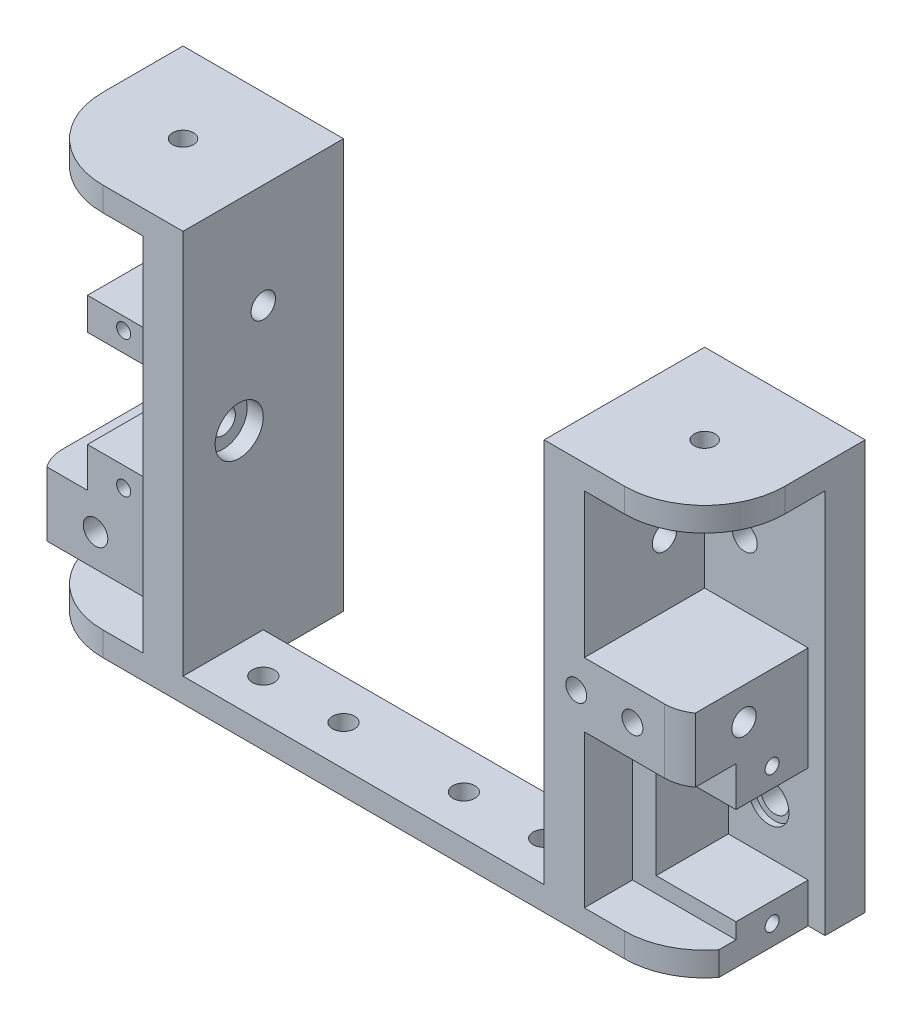
from build123d import *

# Parameters (mm, degrees)
SKETCH1_R                 = 1.75
SKETCH1_R_2               = 1.525
SKETCH1_R_3               = 1.55
MAIN_FLANGE_DEPTH         = 5
SKETCH2_W                 = 15
SKETCH2_H                 = 45
SKETCH2_R                 = 1.525
SIDE_FLANGE_DEPTH         = 5
SKETCH11_R                = 1.3
BOSS_EXTRUDE3_DEPTH       = 3
BOSS_EXTRUDE4_DEPTH       = 7
SKETCH16_R                = 1.3
TOP_SUPPORT_DEPTH         = 3
SKETCH18_W                = 15
SKETCH18_H                = 8
SKETCH18_R                = 1.525
BOSS_EXTRUDE5_DEPTH       = 15
SKETCH19_W                = 15
SKETCH19_H                = 8
SKETCH19_R                = 1.525
BOSS_EXTRUDE6_DEPTH       = 15
FILLET1_R                 = 5
M3X0_5_TAPPED_HOLE1_D     = 2.6
M3X0_5_TAPPED_HOLE1_DEPTH = 7.5
M3X0_5_TAPPED_HOLE1_TIP   = 0.781118805
M3X0_5_TAPPED_HOLE2_D     = 2.6
M3X0_5_TAPPED_HOLE2_DEPTH = 7.5
M3X0_5_TAPPED_HOLE2_TIP   = 0.781118805
SKETCH24_R                = 2.5
CUT_EXTRUDE1_DEPTH        = 0.75
SKETCH25_R                = 2.5
CUT_EXTRUDE2_DEPTH        = 0.75
SKETCH26_W                = 10
SKETCH26_H                = 2.85
BOSS_EXTRUDE7_DEPTH       = 10
MOTOR_MOUNT_DEPTH         = 9
SKETCH33_W                = 15
SKETCH33_H                = 30
CUT_EXTRUDE6_DEPTH        = 2.1
SKETCH34_R                = 0.875
CUT_EXTRUDE7_DEPTH        = 7
BOSS_EXTRUDE9_DEPTH       = 9
SKETCH36_W                = 15
SKETCH36_H                = 29.05
CUT_EXTRUDE8_DEPTH        = 2.1
SKETCH37_R                = 0.875
CUT_EXTRUDE9_DEPTH        = 7
SKETCH39_W                = 45
SKETCH39_H                = 10
CUT_EXTRUDE11_DEPTH       = 52
SKETCH40_R                = 1.375
MOUNT_HOLES_DEPTH         = 4.0000001
SKETCH41_R                = 3
BEARING_HOLDER_DEPTH      = 2
SKETCH42_R                = 3
CUT_EXTRUDE14_DEPTH       = 2


with BuildPart() as part:
    # Sketch1 → main flange (new body)
    with BuildSketch(Plane.XY):
        Polygon((-22.5, 7), (0, 7), (22.5, 7), (22.5, 45), (42.5, 45), (42.5, 0), (-42.5, 0), (-42.5, 45), (-22.5, 45), align=None)
        with Locations((35.5, 8)):
            Circle(SKETCH1_R, mode=Mode.SUBTRACT)
        with Locations((-35.5, 8)):
            Circle(SKETCH1_R_2, mode=Mode.SUBTRACT)
        with Locations((32.5, 35)):
            Circle(SKETCH1_R_3, mode=Mode.SUBTRACT)
        with Locations((-32.5, 35)):
            Circle(SKETCH1_R_3, mode=Mode.SUBTRACT)
    extrude(amount=MAIN_FLANGE_DEPTH)

    # Sketch2 → side flange (add)
    with BuildSketch(Plane(origin=(22.5, 0, 0), x_dir=(0, 0, -1), z_dir=(1, 0, 0))):
        with Locations((-12.5, 22.5)):
            Rectangle(SKETCH2_W, SKETCH2_H)
        with Locations((-13, 23)):
            Circle(SKETCH2_R, mode=Mode.SUBTRACT)
        with Locations((-10, 35)):
            Circle(SKETCH2_R, mode=Mode.SUBTRACT)
    side_flange = extrude(amount=SIDE_FLANGE_DEPTH)

    # Mirror1: side flange across plane
    add(side_flange.mirror(Plane(origin=(0, 0, 0), x_dir=(0, 0, 1), z_dir=(1, 0, 0))))

    # Sketch11 → Boss-Extrude3 (add)
    with BuildSketch(Plane.XZ):
        with BuildLine():
            Line((-42.5, 0), (42.5, 0))
            Line((42.5, 0), (42.5, 10))
            ThreePointArc((42.5, 10), (39.571067812, 17.071067812), (32.5, 20))
            Line((32.5, 20), (-32.5, 20))
            ThreePointArc((-32.5, 20), (-39.571067812, 17.071067812), (-42.5, 10))
            Line((-42.5, 10), (-42.5, 0))
        make_face()
        with Locations((-32.5, 10)):
            Circle(SKETCH11_R, mode=Mode.SUBTRACT)
        with Locations((32.5, 10)):
            Circle(SKETCH11_R, mode=Mode.SUBTRACT)
    extrude(amount=BOSS_EXTRUDE3_DEPTH)

    # Sketch12 → Boss-Extrude4 (add)
    with BuildSketch(Plane(origin=(0, 0, 0), x_dir=(1, 0, 0), z_dir=(0, 1, 0))):
        with BuildLine():
            Line((-4, -3), (-4, 0))
            Line((-4, 0), (4, 0))
            Line((4, 0), (4, -3))
            ThreePointArc((4, -3), (0, -7), (-4, -3))
        make_face()
    extrude(amount=BOSS_EXTRUDE4_DEPTH)

    # Sketch15 → CSK for M3 Flat Head Machine Screw1 (revolve, cut)
    with BuildSketch(Plane(origin=(0, -3, 3), x_dir=(0, 0, -1), z_dir=(1, 0, 0))):
        Polygon((0, 0), (0, 10), (1.8, 10), (1.8, 1.5), (3.15, 0.15), (3.15, 0), align=None)
    revolve(axis=Axis((0, -9.35, 3), (0, 1, 0)), mode=Mode.SUBTRACT)

    # Sketch16 → Top support (add)
    with BuildSketch(Plane(origin=(0, 45, 0), x_dir=(1, 0, 0), z_dir=(0, 1, 0))):
        with BuildLine():
            Line((-42.5, 0), (-22.5, 0))
            Line((-22.5, 0), (-22.5, -20))
            Line((-22.5, -20), (-32.5, -20))
            ThreePointArc((-32.5, -20), (-39.571067812, -17.071067812), (-42.5, -10))
            Line((-42.5, -10), (-42.5, 0))
        make_face()
        with Locations((-32.5, -10)):
            Circle(SKETCH16_R, mode=Mode.SUBTRACT)
        with BuildLine():
            Line((42.5, 0), (42.5, -10))
            ThreePointArc((42.5, -10), (39.571067812, -17.071067812), (32.5, -20))
            Line((32.5, -20), (22.5, -20))
            Line((22.5, -20), (22.5, 0))
            Line((22.5, 0), (42.5, 0))
        make_face()
        with Locations((32.5, -10)):
            Circle(SKETCH16_R, mode=Mode.SUBTRACT)
    extrude(amount=TOP_SUPPORT_DEPTH)

    # Sketch18 → Boss-Extrude5 (add)
    with BuildSketch(Plane(origin=(27.5, 0, 0), x_dir=(0, 0, -1), z_dir=(1, 0, 0))):
        with Locations((-12.5, 23)):
            Rectangle(SKETCH18_W, SKETCH18_H)
        with Locations((-13, 23)):
            Circle(SKETCH18_R, mode=Mode.SUBTRACT)
    extrude(amount=BOSS_EXTRUDE5_DEPTH)

    # Sketch19 → Boss-Extrude6 (add)
    with BuildSketch(Plane.XY.offset(5)):
        with Locations((-35, 8)):
            Rectangle(SKETCH19_W, SKETCH19_H)
        with Locations((-35.5, 8)):
            Circle(SKETCH19_R, mode=Mode.SUBTRACT)
    extrude(amount=BOSS_EXTRUDE6_DEPTH)

    # Fillet1
    fillet1_edges = [part.edges().sort_by_distance(p)[0] for p in [
        (42.5, 23, 20),
        (-42.5, 8, 20),
    ]]
    fillet(fillet1_edges, radius=FILLET1_R)

    # M3x0.5 Tapped Hole1
    with Locations(Plane.ZY.offset(42.5)):
        with Locations((11, 8), (4, 8)):
            Hole(M3X0_5_TAPPED_HOLE1_D / 2, depth=M3X0_5_TAPPED_HOLE1_DEPTH)
            with Locations((0, 0, -(M3X0_5_TAPPED_HOLE1_DEPTH + M3X0_5_TAPPED_HOLE1_TIP / 2))):  # 118° drill point
                Cone(0, M3X0_5_TAPPED_HOLE1_D / 2, M3X0_5_TAPPED_HOLE1_TIP, mode=Mode.SUBTRACT)

    # M3x0.5 Tapped Hole2
    with Locations(Plane.XY.offset(20)):
        with Locations((33.5, 23), (26.5, 23)):
            Hole(M3X0_5_TAPPED_HOLE2_D / 2, depth=M3X0_5_TAPPED_HOLE2_DEPTH)
            with Locations((0, 0, -(M3X0_5_TAPPED_HOLE2_DEPTH + M3X0_5_TAPPED_HOLE2_TIP / 2))):  # 118° drill point
                Cone(0, M3X0_5_TAPPED_HOLE2_D / 2, M3X0_5_TAPPED_HOLE2_TIP, mode=Mode.SUBTRACT)

    # Sketch24 → Cut-Extrude1 (cut)
    with BuildSketch(Plane.XY.offset(5)):
        with Locations((35.5, 8)):
            Circle(SKETCH24_R)
    extrude(amount=-CUT_EXTRUDE1_DEPTH, mode=Mode.SUBTRACT)

    # Sketch25 → Cut-Extrude2 (cut)
    with BuildSketch(Plane.ZY.offset(27.5)):
        with Locations((13, 23)):
            Circle(SKETCH25_R)
    extrude(amount=-CUT_EXTRUDE2_DEPTH, mode=Mode.SUBTRACT)

    # Sketch26 → Boss-Extrude7 (add)
    with BuildSketch(Plane(origin=(0, 7, 0), x_dir=(1, 0, 0), z_dir=(0, 1, 0))):
        with Locations((-10.2, -1.425)):
            Rectangle(SKETCH26_W, SKETCH26_H)
        with Locations((10.2, -1.425)):
            Rectangle(SKETCH26_W, SKETCH26_H)
    extrude(amount=BOSS_EXTRUDE7_DEPTH)

    # Sketch32 → Motor mount (add)
    with BuildSketch(Plane.XY.offset(5)):
        Polygon((40.4, 14.05), (30.45, 14.05), (30.45, 1.95), (40.4, 1.95), (40.4, 0), (27.5, 0), (27.5, 19), (40.4, 19), align=None)
    extrude(amount=MOTOR_MOUNT_DEPTH)

    # Sketch33 → Cut-Extrude6 (cut)
    with BuildSketch(Plane(origin=(42.5, 0, 0), x_dir=(0, 0, -1), z_dir=(1, 0, 0))):
        with Locations((-12.5, 12)):
            Rectangle(SKETCH33_W, SKETCH33_H)
    extrude(amount=-CUT_EXTRUDE6_DEPTH, mode=Mode.SUBTRACT)

    # Sketch34 → Cut-Extrude7 (cut)
    with BuildSketch(Plane(origin=(40.4, 0, 0), x_dir=(0, 0, -1), z_dir=(1, 0, 0))):
        with Locations((-9.5, 16.5)):
            Circle(SKETCH34_R)
        with Locations((-9.5, -0.5)):
            Circle(SKETCH34_R)
    extrude(amount=-CUT_EXTRUDE7_DEPTH, mode=Mode.SUBTRACT)

    # Sketch35 → Boss-Extrude9 (add)
    with BuildSketch(Plane.ZY.offset(27.5)):
        Polygon((20, 29.05), (7.95, 29.05), (7.95, 16.95), (20, 16.95), (20, 12), (5, 12), (5, 33.05), (20, 33.05), align=None)
    extrude(amount=BOSS_EXTRUDE9_DEPTH)

    # Sketch36 → Cut-Extrude8 (cut)
    with BuildSketch(Plane.XY.offset(20)):
        with Locations((-35, 18.525)):
            Rectangle(SKETCH36_W, SKETCH36_H)
    extrude(amount=-CUT_EXTRUDE8_DEPTH, mode=Mode.SUBTRACT)

    # Sketch37 → Cut-Extrude9 (cut)
    with BuildSketch(Plane.XY.offset(17.9)):
        with Locations((-32, 31.5)):
            Circle(SKETCH37_R)
        with Locations((-32, 14.5)):
            Circle(SKETCH37_R)
    extrude(amount=-CUT_EXTRUDE9_DEPTH, mode=Mode.SUBTRACT)

    # Sketch39 → Cut-Extrude11 (cut, through all)
    with BuildSketch(Plane.XZ.offset(3)):
        with Locations((0, 5)):
            Rectangle(SKETCH39_W, SKETCH39_H)
    extrude(amount=-CUT_EXTRUDE11_DEPTH, mode=Mode.SUBTRACT)

    # Sketch40 → Mount Holes (cut, through all)
    with BuildSketch(Plane(origin=(0, 0, 0), x_dir=(1, 0, 0), z_dir=(0, 1, 0))):
        with Locations((-17.5, -15)):
            Circle(SKETCH40_R)
        with Locations((-7.5, -15)):
            Circle(SKETCH40_R)
        with Locations((7.5, -15)):
            Circle(SKETCH40_R)
        with Locations((17.5, -15)):
            Circle(SKETCH40_R)
    extrude(amount=-MOUNT_HOLES_DEPTH, mode=Mode.SUBTRACT)

    # Sketch41 → Bearing Holder (cut)
    with BuildSketch(Plane(origin=(-22.5, 0, 0), x_dir=(0, 0, -1), z_dir=(1, 0, 0))):
        with Locations((-13, 23)):
            Circle(SKETCH41_R)
    extrude(amount=-BEARING_HOLDER_DEPTH, mode=Mode.SUBTRACT)

    # Sketch42 → Cut-Extrude14 (cut)
    with BuildSketch(Plane(origin=(0, 0, 0), x_dir=(-1, 0, 0), z_dir=(0, 0, -1))):
        with Locations((-35.5, 8)):
            Circle(SKETCH42_R)
    extrude(amount=-CUT_EXTRUDE14_DEPTH, mode=Mode.SUBTRACT)


solid = part.part
